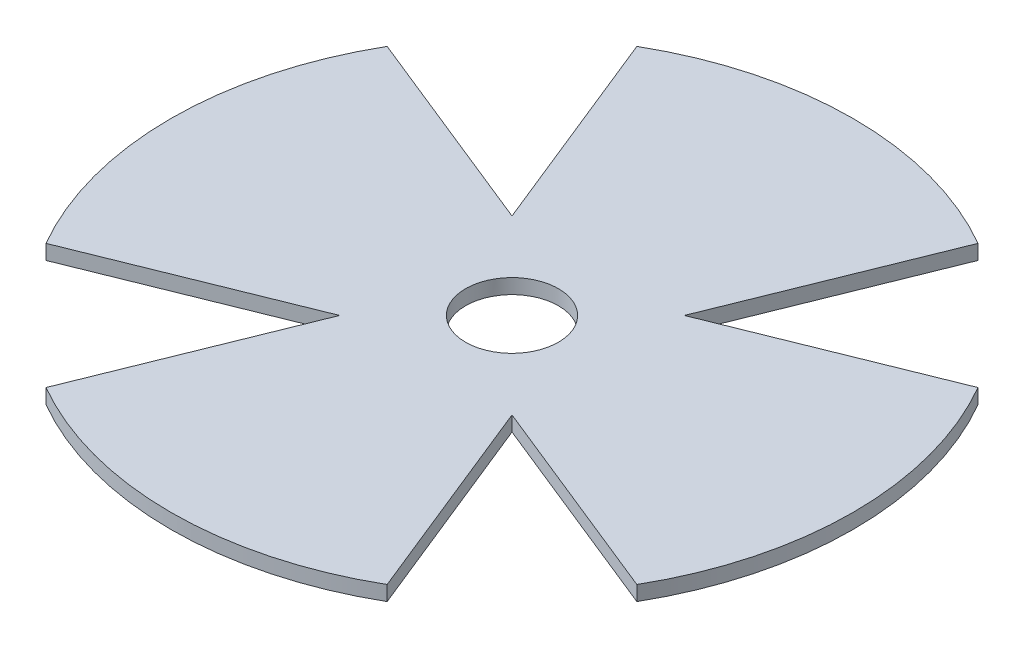
from build123d import *

# Parameters (mm, degrees)
BOSS_EXTRUDE1_DEPTH     = 1.52
SKETCH2_R               = 4.7625
CUT_EXTRUDE5_DEPTH      = 2.52
CUT_EXTRUDE5_DEPTH_BACK = 1


with BuildPart() as part:
    # Sketch1 → Boss-Extrude1 (new body)
    with BuildSketch(Plane(origin=(0, 0, 0), x_dir=(1, 0, 0), z_dir=(0, 1, 0))):
        with BuildLine():
            Line((-17.5, 30.310889132), (-17.5, 17.5))
            Line((-17.5, 17.5), (-30.310889132, 17.5))
            ThreePointArc((-30.310889132, 17.5), (-35, 0), (-30.310889132, -17.5))
            Line((-30.310889132, -17.5), (-17.5, -17.5))
            Line((-17.5, -17.5), (-17.5, -30.310889132))
            ThreePointArc((-17.5, -30.310889132), (0, -35), (17.5, -30.310889132))
            Line((17.5, -30.310889132), (17.5, -17.5))
            Line((17.5, -17.5), (30.310889132, -17.5))
            ThreePointArc((30.310889132, -17.5), (35, 0), (30.310889132, 17.5))
            Line((30.310889132, 17.5), (17.5, 17.5))
            Line((17.5, 17.5), (17.5, 30.310889132))
            ThreePointArc((17.5, 30.310889132), (0, 35), (-17.5, 30.310889132))
        make_face()
    extrude(amount=BOSS_EXTRUDE1_DEPTH)

    # Sketch2 → Cut-Extrude5 (cut, two sides)
    with BuildSketch(Plane(origin=(0, 0, 0), x_dir=(1, 0, 0), z_dir=(0, 1, 0))) as cut_extrude5_sk:
        Circle(SKETCH2_R)
        Polygon((-30.310889132, 17.5), (-17.5, 30.310889132), (-8.838834765, 8.838834765), align=None)
        Polygon((17.5, 30.310889132), (30.310889132, 17.5), (8.838834765, 8.838834765), align=None)
        Polygon((30.310889132, -17.5), (17.5, -30.310889132), (8.838834765, -8.838834765), align=None)
        Polygon((-30.310889132, -17.5), (-17.5, -30.310889132), (-8.838834765, -8.838834765), align=None)
    extrude(amount=CUT_EXTRUDE5_DEPTH, mode=Mode.SUBTRACT)
    extrude(cut_extrude5_sk.sketch, amount=-CUT_EXTRUDE5_DEPTH_BACK, mode=Mode.SUBTRACT)


solid = part.part
